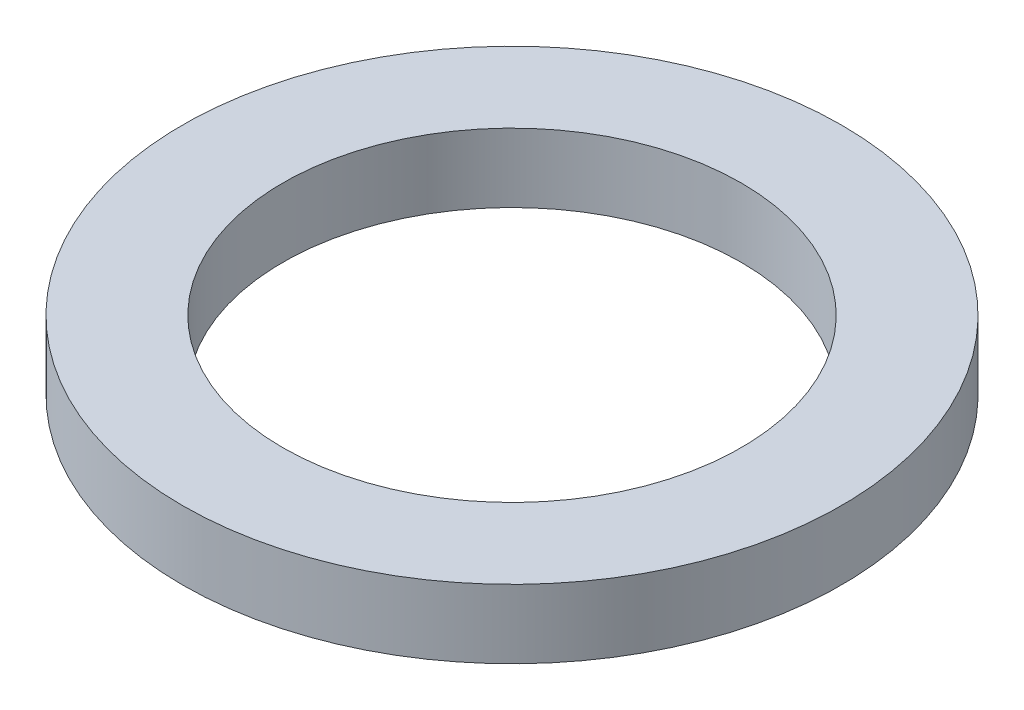
from build123d import *

# Parameters (mm, degrees)
SKETCH1_R           = 5.75
SKETCH1_R_2         = 4
BOSS_EXTRUDE1_DEPTH = 1.2


with BuildPart() as part:
    # Sketch1 → Boss-Extrude1 (new body)
    with BuildSketch(Plane(origin=(0, 0, 0), x_dir=(1, 0, 0), z_dir=(0, 1, 0))):
        Circle(SKETCH1_R)
        Circle(SKETCH1_R_2, mode=Mode.SUBTRACT)
    extrude(amount=BOSS_EXTRUDE1_DEPTH)


solid = part.part
